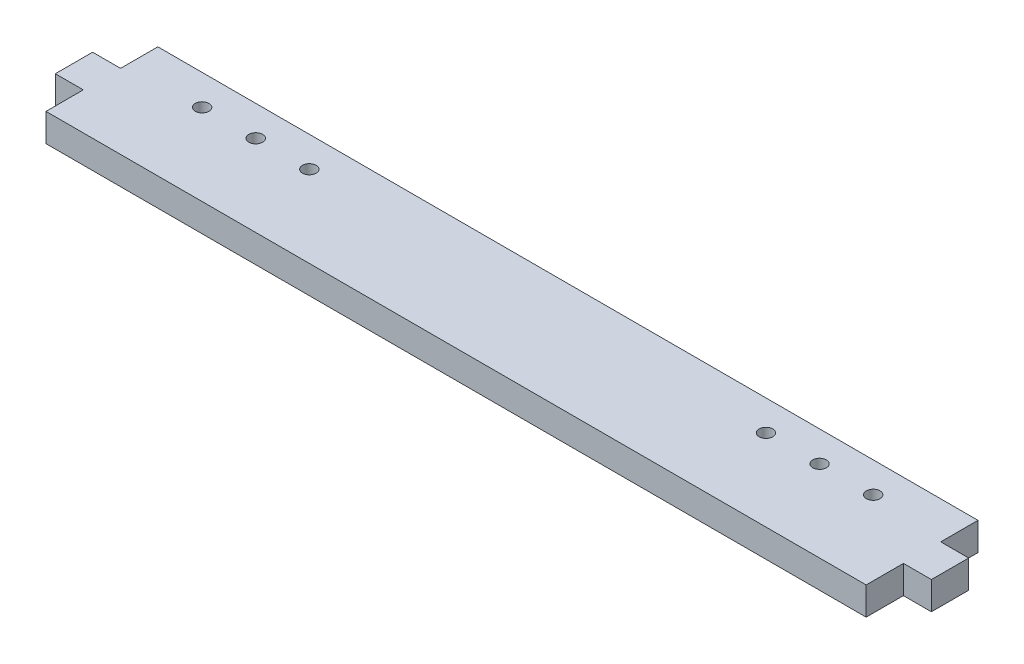
from build123d import *

# Parameters (mm, degrees)
SKETCH1_W           = 279.4
SKETCH1_H           = 38.1
BOSS_EXTRUDE1_DEPTH = 9.525
SKETCH2_W           = 12.7
SKETCH2_H           = 9.525
BOSS_EXTRUDE2_DEPTH = 9.525
SKETCH3_R           = 2.3368
CUT_EXTRUDE1_DEPTH  = 10.525


with BuildPart() as part:
    # Sketch1 → Boss-Extrude1 (new body)
    with BuildSketch(Plane(origin=(0, 0, 0), x_dir=(1, 0, 0), z_dir=(0, 1, 0))):
        Rectangle(SKETCH1_W, SKETCH1_H)
    extrude(amount=BOSS_EXTRUDE1_DEPTH)

    # Sketch2 → Boss-Extrude2 (add)
    with BuildSketch(Plane(origin=(139.7, 0, 0), x_dir=(0, 0, -1), z_dir=(1, 0, 0))):
        with Locations((0, 4.7625)):
            Rectangle(SKETCH2_W, SKETCH2_H)
    boss_extrude2 = extrude(amount=BOSS_EXTRUDE2_DEPTH)

    # Mirror1: Boss-Extrude2 across plane
    add(boss_extrude2.mirror(Plane(origin=(0, 0, 0), x_dir=(0, 0, 1), z_dir=(1, 0, 0))))

    # Sketch3 → Cut-Extrude1 (cut, through all)
    with BuildSketch(Plane.XZ):
        with Locations((114.3, -8.7376)):
            Circle(SKETCH3_R)
        with Locations((77.7748, -8.7376)):
            Circle(SKETCH3_R)
        with Locations((96.0374, -8.7376)):
            Circle(SKETCH3_R)
    cut_extrude1 = extrude(amount=-CUT_EXTRUDE1_DEPTH, mode=Mode.SUBTRACT)

    # Mirror2: Cut-Extrude1 across plane
    add(cut_extrude1.mirror(Plane(origin=(0, 0, 0), x_dir=(0, 0, 1), z_dir=(1, 0, 0))), mode=Mode.SUBTRACT)


solid = part.part
